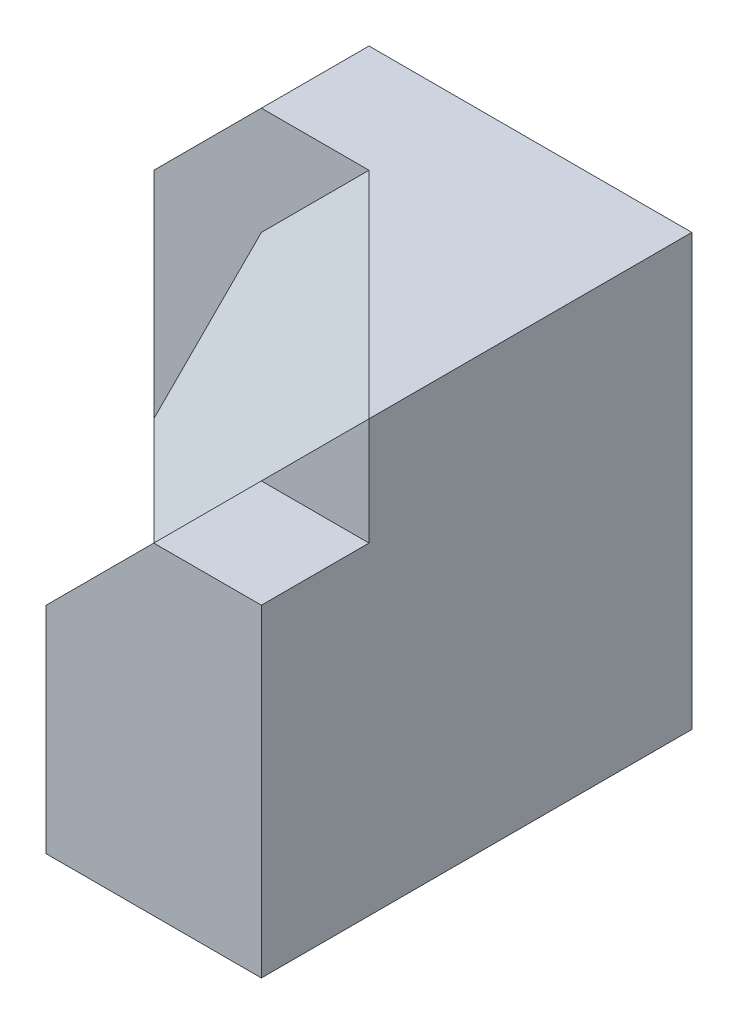
from build123d import *

# Parameters (mm, degrees)
BOSS_EXTRUDE1_DEPTH = 20
SKETCH2_W           = 5
SKETCH2_H           = 20
BOSS_EXTRUDE2_DEPTH = 5
CUT_EXTRUDE1_DEPTH  = 5
SKETCH4_W           = 5
SKETCH4_H           = 5
BOSS_EXTRUDE3_DEPTH = 5
CUT_EXTRUDE2_DEPTH  = 5
BOSS_EXTRUDE4_DEPTH = 20
CUT_EXTRUDE3_DEPTH  = 20
BOSS_EXTRUDE5_DEPTH = 5


with BuildPart() as part:
    # Sketch1 → Boss-Extrude1 (new body)
    with BuildSketch(Plane(origin=(0, 0, 0), x_dir=(1, 0, 0), z_dir=(0, 1, 0))):
        Polygon((-23.656387665, 13.90969163), (-8.656387665, 13.90969163), (-8.656387665, -1.09030837), (-18.656387665, 8.90969163), (-23.656387665, 8.90969163), align=None)
    extrude(amount=BOSS_EXTRUDE1_DEPTH)

    # Sketch2 → Boss-Extrude2 (add)
    with BuildSketch(Plane.ZY.offset(23.656387665)):
        with Locations((-11.40969163, 10)):
            Rectangle(SKETCH2_W, SKETCH2_H)
    extrude(amount=BOSS_EXTRUDE2_DEPTH)

    # Sketch3 → Cut-Extrude1 (cut)
    with BuildSketch(Plane.XY.offset(-8.90969163)):
        Polygon((-23.656387665, 20), (-28.656387665, 15), (-28.656387665, 20), align=None)
    extrude(amount=-CUT_EXTRUDE1_DEPTH, mode=Mode.SUBTRACT)

    # Sketch4 → Boss-Extrude3 (add)
    with BuildSketch(Plane.XY.offset(-8.90969163)):
        with Locations((-26.156387665, 2.5)):
            Rectangle(SKETCH4_W, SKETCH4_H)
    extrude(amount=BOSS_EXTRUDE3_DEPTH)

    # Sketch5 → Cut-Extrude2 (cut)
    with BuildSketch(Plane(origin=(0, 5, 0), x_dir=(1, 0, 0), z_dir=(0, 1, 0))):
        Polygon((-28.656387665, 8.90969163), (-23.656387665, 3.90969163), (-28.656387665, 3.90969163), align=None)
    extrude(amount=-CUT_EXTRUDE2_DEPTH, mode=Mode.SUBTRACT)

    # Sketch6 → Boss-Extrude4 (add)
    with BuildSketch(Plane(origin=(0, 0, 0), x_dir=(-1, 0, 0), z_dir=(0, -1, 0))):
        Polygon((18.656387665, -1.09030837), (23.656387665, 3.90969163), (23.656387665, 8.90969163), (18.656387665, 8.90969163), (8.656387665, -1.09030837), align=None)
    extrude(amount=-BOSS_EXTRUDE4_DEPTH)

    # 3DSketch1 → Cut-Extrude3 (cut, along a direction that is not the sketch's normal)
    with BuildSketch(Plane(origin=(-8.656387665, 20, 1.09030837), x_dir=(-0.8017837257372731, -0.26726124191242434, -0.5345224838248491), z_dir=(-0.577350269189626, 0.577350269189626, 0.5773502691896256))):
        Polygon((0, 0), (13.363062096, -4.629100499), (18.708286934, 0), (17.371980724, 6.943650748), (10.690449676, 9.258200998), align=None)
    extrude(amount=CUT_EXTRUDE3_DEPTH, dir=(0, 1, 0), mode=Mode.SUBTRACT)

    # Sketch7 → Boss-Extrude5 (add)
    with BuildSketch(Plane.XY.offset(1.09030837)):
        Polygon((-8.656387665, 15), (-13.656387665, 15), (-18.656387665, 10), (-18.656387665, 0), (-8.656387665, 0), align=None)
    extrude(amount=BOSS_EXTRUDE5_DEPTH)


solid = part.part
